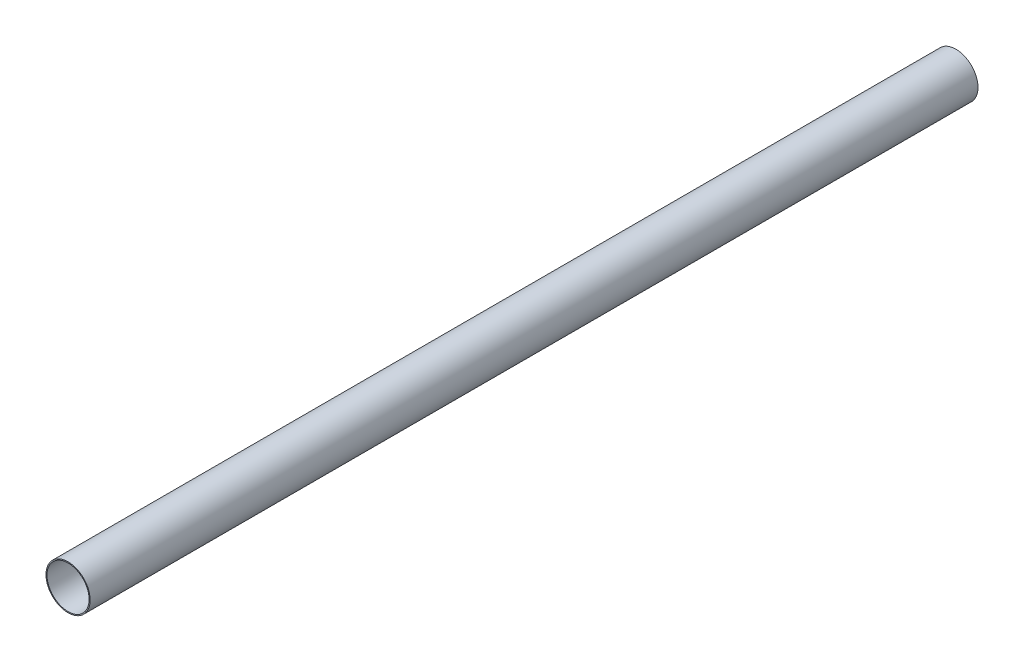
from build123d import *

# Parameters (mm, degrees)
PIPESKETCH_R    = 136.525
PIPESKETCH_R_2  = 130.175
EXTRUSION_DEPTH = 5486.4


with BuildPart() as part:
    # PipeSketch → Extrusion (new body)
    with BuildSketch(Plane.XY):
        Circle(PIPESKETCH_R)
        Circle(PIPESKETCH_R_2, mode=Mode.SUBTRACT)
    extrude(amount=EXTRUSION_DEPTH)


solid = part.part
